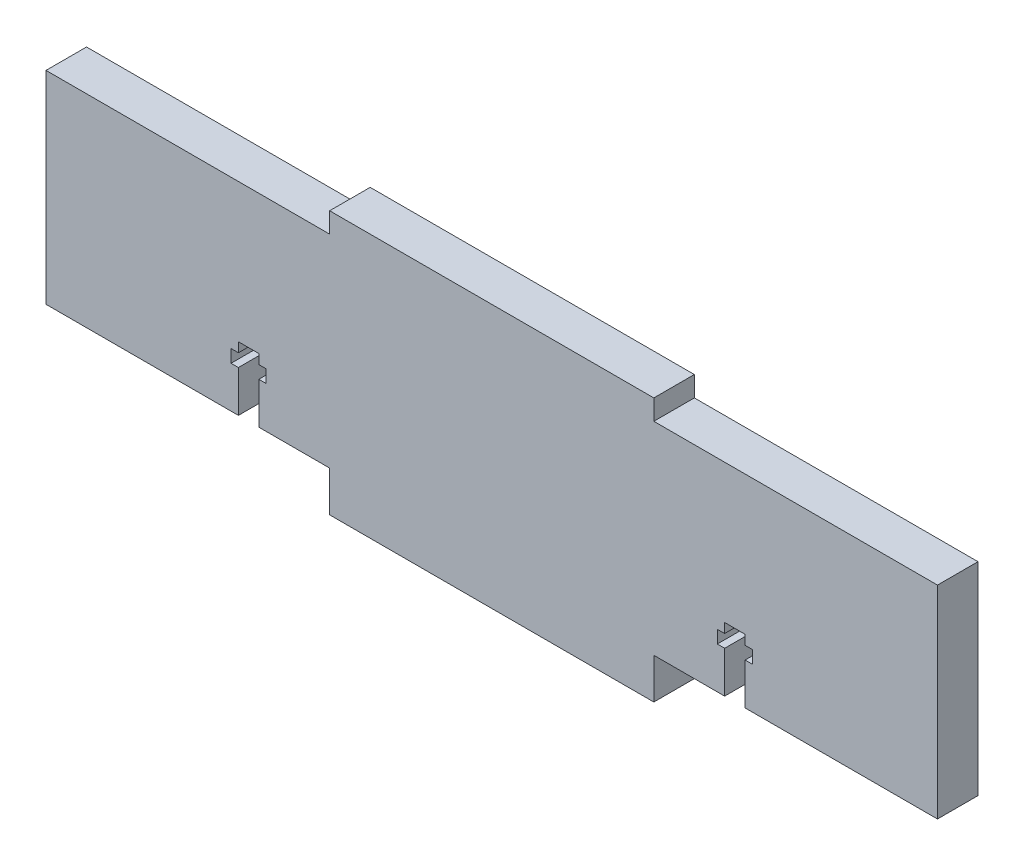
from build123d import *

# Parameters (mm, degrees)
BOSS_EXTRUDE1_DEPTH = 6.35
CUT_EXTRUDE1_DEPTH  = 7.35


with BuildPart() as part:
    # Sketch1 → Boss-Extrude1 (new body)
    with BuildSketch(Plane.XY):
        Polygon((0, 0), (44.45, 0), (44.45, -6.35), (95.25, -6.35), (95.25, 0), (139.7, 0), (139.7, 31.75), (95.25, 31.75), (95.25, 34.925), (44.45, 34.925), (44.45, 31.75), (0, 31.75), align=None)
    extrude(amount=BOSS_EXTRUDE1_DEPTH)

    # Sketch2 → Cut-Extrude1 (cut, through all)
    with BuildSketch(Plane.XY.offset(6.35)):
        Polygon((30.15, 0), (33.35, 0), (33.35, 6.5), (34.5, 6.5), (34.5, 8.5), (33.35, 8.5), (33.35, 10), (30.15, 10), (30.15, 8.5), (29, 8.5), (29, 6.5), (30.15, 6.5), align=None)
        Polygon((109.55, 8.5), (109.55, 10), (106.35, 10), (106.35, 8.5), (105.2, 8.5), (105.2, 6.5), (106.35, 6.5), (106.35, 0), (109.55, 0), (109.55, 6.5), (110.7, 6.5), (110.7, 8.5), align=None)
    extrude(amount=-CUT_EXTRUDE1_DEPTH, mode=Mode.SUBTRACT)


solid = part.part
